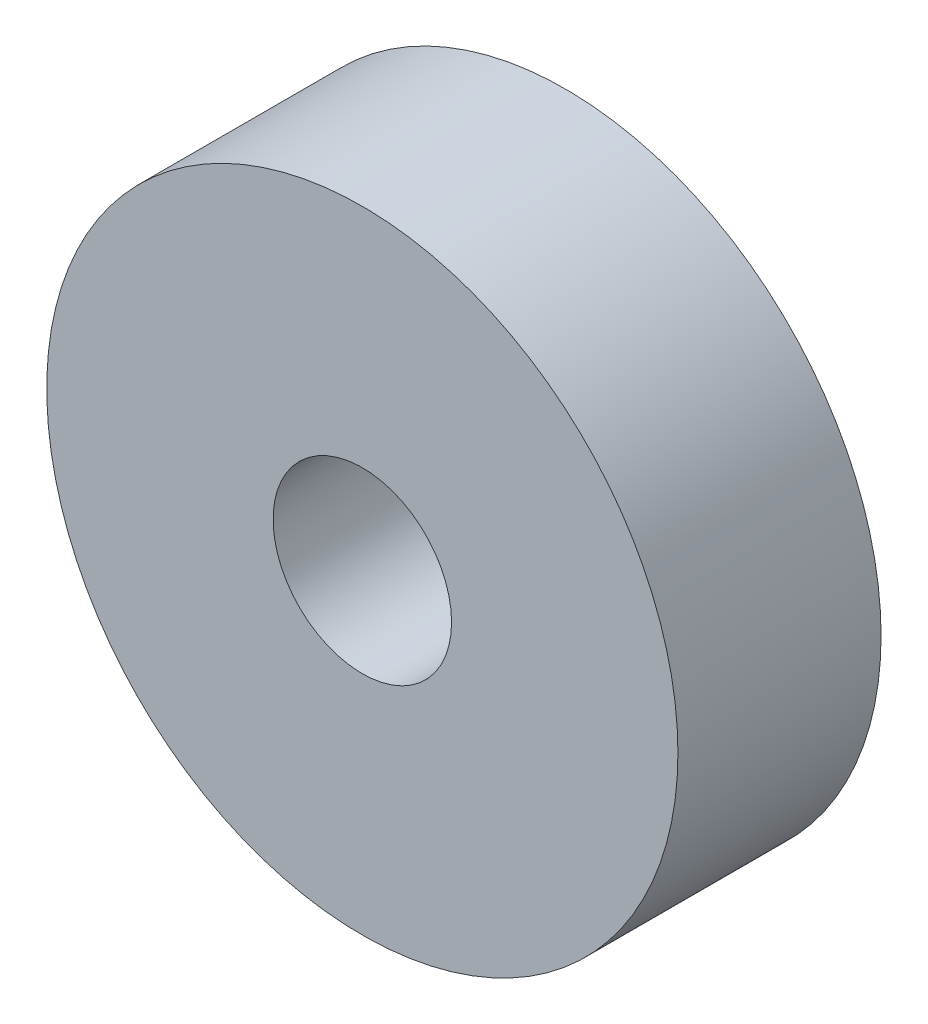
from build123d import *

# Parameters (mm, degrees)
SKETCH1_R           = 10.875
SKETCH1_R_2         = 3.075
BOSS_EXTRUDE1_DEPTH = 7


with BuildPart() as part:
    # Sketch1 → Boss-Extrude1 (new body)
    with BuildSketch(Plane.XY):
        Circle(SKETCH1_R)
        Circle(SKETCH1_R_2, mode=Mode.SUBTRACT)
    extrude(amount=BOSS_EXTRUDE1_DEPTH)


solid = part.part
